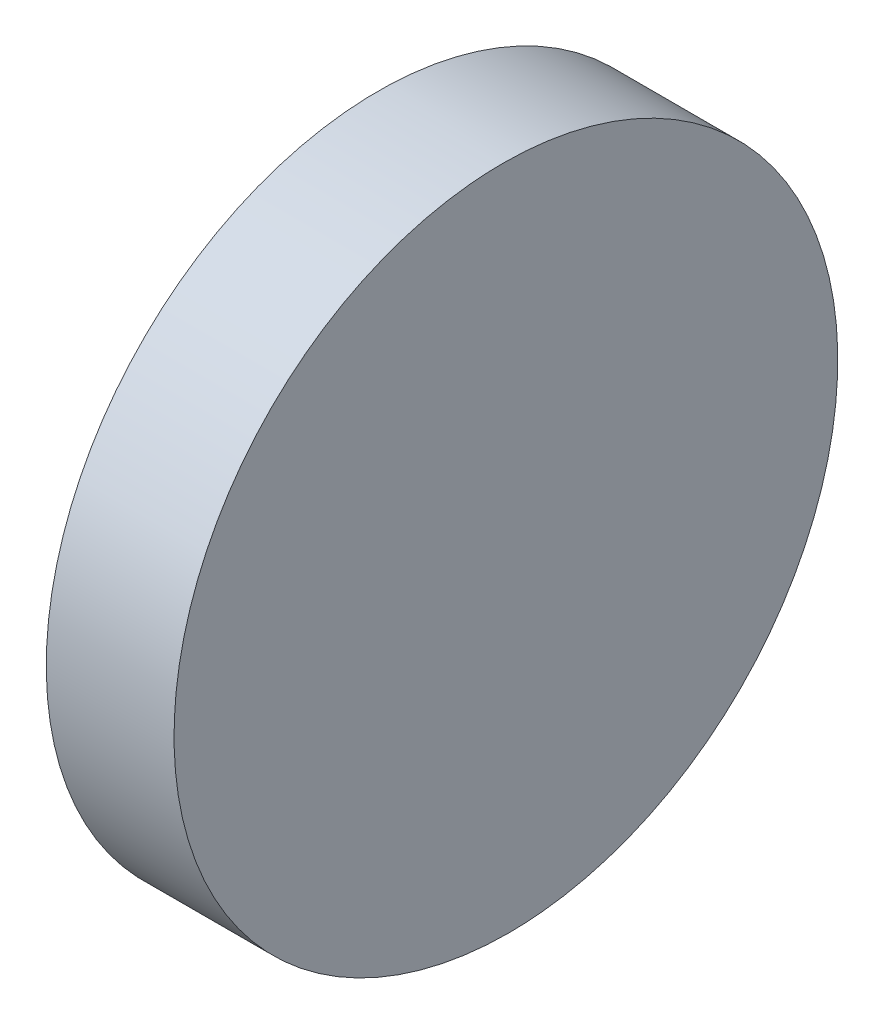
from build123d import *

# Parameters (mm, degrees)
EXTRUDE_1_DEPTH     = 50.8
CUT_EXTRUDE_1_DEPTH = 10


with BuildPart() as part:
    # 草图1 → 凸台-拉伸1 (new body)
    with BuildSketch(Plane.XY):
        Polygon((0, 25.4), (0, -25.4), (10, -25.4), (9.556675116, 25.4), align=None)
    extrude(amount=EXTRUDE_1_DEPTH)

    # 草图2 → 切除-拉伸1 (cut)
    with BuildSketch(Plane.ZY):
        with BuildLine():
            ThreePointArc((25.4, -25.4), (7.439487746, -17.96051223), (0, 3.4e-08))
            Line((0, 3.4e-08), (0, -25.4))
            Line((0, -25.4), (25.4, -25.4))
        make_face()
        with BuildLine():
            ThreePointArc((50.8, 0), (43.360512242, -17.960512242), (25.4, -25.4))
            Line((25.4, -25.4), (50.8, -25.4))
            Line((50.8, -25.4), (50.8, 0))
        make_face()
        with BuildLine():
            Line((50.8, 25.4), (25.4, 25.4))
            ThreePointArc((25.4, 25.4), (43.360512242, 17.960512242), (50.8, 0))
            Line((50.8, 0), (50.8, 25.4))
        make_face()
        with BuildLine():
            Line((25.4, 25.4), (0, 25.4))
            Line((0, 25.4), (0, 3.4e-08))
            ThreePointArc((0, 3.4e-08), (7.43948777, 17.960512254), (25.4, 25.4))
        make_face()
    extrude(amount=-CUT_EXTRUDE_1_DEPTH, mode=Mode.SUBTRACT)


solid = part.part
